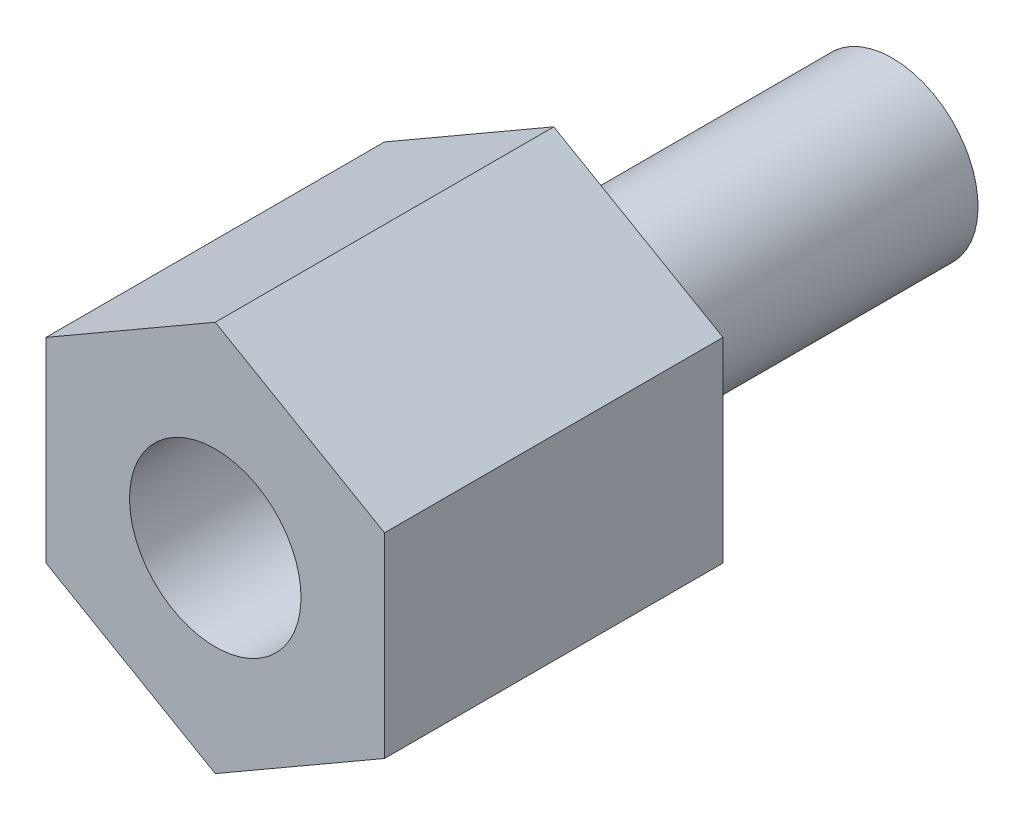
from build123d import *

# Parameters (mm, degrees)
SKETCH4_R           = 3.58775
BOSS_EXTRUDE1_DEPTH = 9.525


with BuildPart() as part:
    # Sketch3 → Revolve1 (revolve)
    with BuildSketch(Plane(origin=(0, 0, 0), x_dir=(0, 0, -1), z_dir=(1, 0, 0))):
        Polygon((-4.7498, 2.413), (-4.7498, 0), (9.525, 0), (9.525, 2.413), (1.44065625, 2.413), (1.143, 1.897444252), (0, 1.897444252), (0, 4.7625), (-9.525, 4.7625), (-9.525, 2.413), align=None)
    revolve(axis=Axis((0, 0, -9.525), (0, 0, 1)))

    # Sketch4 → Boss-Extrude1 (add)
    with BuildSketch(Plane.XY.offset(9.525)):
        Polygon((-4.7625, 2.749630657), (-4.7625, -2.749630657), (0, -5.499261314), (4.7625, -2.749630657), (4.7625, 2.749630657), (0, 5.499261314), align=None)
        Circle(SKETCH4_R, mode=Mode.SUBTRACT)
    extrude(amount=-BOSS_EXTRUDE1_DEPTH)


solid = part.part
